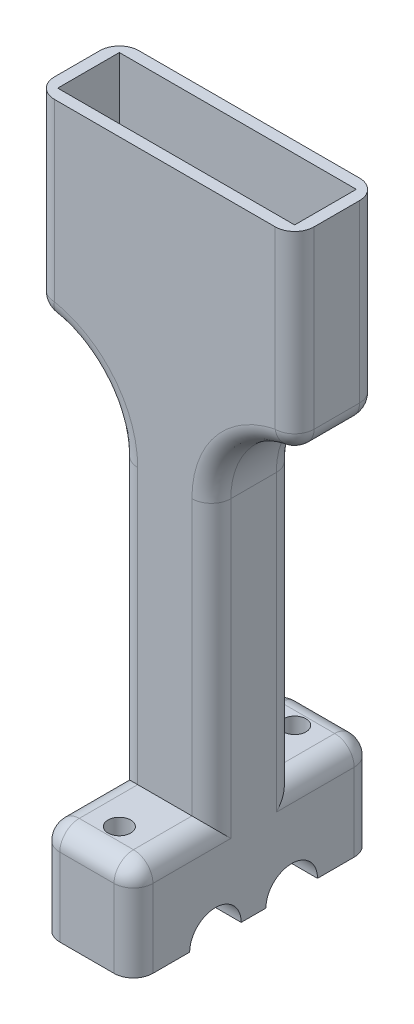
from build123d import *

# Parameters (mm, degrees)
RESSALTO_EXTRUS_O1_DEPTH = 6.5
FILETE1_R                = 3
FILETE2_R                = 3
FILETE3_R                = 13
ESBO_O4_W                = 36.5
ESBO_O4_H                = 9.5
CORTE_EXTRUS_O1_DEPTH    = 25
ESBO_O11_W               = 14.347963754
ESBO_O11_H               = 15
RESSALTO_EXTRUS_O5_DEPTH = 12
ESBO_O17_W               = 14.347963754
ESBO_O17_H               = 15
RESSALTO_EXTRUS_O6_DEPTH = 12
ESBO_O18_R               = 1.75
CORTE_EXTRUS_O5_DEPTH    = 25
ESBO_O19_R               = 3.96875
CORTE_EXTRUS_O6_DEPTH    = 25
FILETE14_R               = 3


with BuildPart() as part:
    # Esboço2 → Ressalto-extrusão1 (new body, symmetric)
    with BuildSketch(Plane.XY):
        Polygon((-20, 50), (20, 50), (20, 20), (7.173981877, 20), (7.173981877, -50), (-7.173981877, -50), (-7.173981877, 20), (-20, 20), align=None)
    extrude(amount=RESSALTO_EXTRUS_O1_DEPTH, both=True)

    # Filete1
    filete1_edges = [part.edges().sort_by_distance(p)[0] for p in [
        (-20, 20, 0),
    ]]
    fillet(filete1_edges, radius=FILETE1_R)

    # Filete2
    filete2_edges = [part.edges().sort_by_distance(p)[0] for p in [
        (20, 20, 0),
    ]]
    fillet(filete2_edges, radius=FILETE2_R)

    # Filete3
    filete3_edges = [part.edges().sort_by_distance(p)[0] for p in [
        (-7.173981877, 20, 0),
        (7.173981877, 20, 0),
    ]]
    fillet(filete3_edges, radius=FILETE3_R)

    # Esboço4 → Corte-extrusão1 (cut)
    with BuildSketch(Plane(origin=(0, 50, 0), x_dir=(1, 0, 0), z_dir=(0, 1, 0))):
        Rectangle(ESBO_O4_W, ESBO_O4_H)
    extrude(amount=-CORTE_EXTRUS_O1_DEPTH, mode=Mode.SUBTRACT)

    # Esboço11 → Ressalto-extrusão5 (add)
    with BuildSketch(Plane.XY.offset(6.5)):
        with Locations((0, -42.5)):
            Rectangle(ESBO_O11_W, ESBO_O11_H)
    extrude(amount=RESSALTO_EXTRUS_O5_DEPTH)

    # Esboço17 → Ressalto-extrusão6 (add)
    with BuildSketch(Plane(origin=(0, 0, -6.5), x_dir=(-1, 0, 0), z_dir=(0, 0, -1))):
        with Locations((0, -42.5)):
            Rectangle(ESBO_O17_W, ESBO_O17_H)
    extrude(amount=RESSALTO_EXTRUS_O6_DEPTH)

    # Esboço18 → Corte-extrusão5 (cut)
    with BuildSketch(Plane.XZ.offset(50)):
        with Locations((0, 13.5)):
            Circle(ESBO_O18_R)
        with Locations((0, -13.5)):
            Circle(ESBO_O18_R)
    extrude(amount=-CORTE_EXTRUS_O5_DEPTH, mode=Mode.SUBTRACT)

    # Esboço19 → Corte-extrusão6 (cut)
    with BuildSketch(Plane.ZY.offset(7.173981877)):
        with Locations((-5.875, -50)):
            Circle(ESBO_O19_R)
        with Locations((5.875, -50)):
            Circle(ESBO_O19_R)
    extrude(amount=-CORTE_EXTRUS_O6_DEPTH, mode=Mode.SUBTRACT)

    # Filete14
    filete14_edges = [part.edges().sort_by_distance(p)[0] for p in [
        (20, 36.5, 6.5),
        (19.322214978, 21.100706027, 6.5),
        (10.111050307, 15.548251086, 6.5),
        (-20, 36.5, 6.5),
        (-19.322214978, 21.100706027, 6.5),
        (-10.111050307, 15.548251086, 6.5),
        (20, 36.5, -6.5),
        (19.322214978, 21.100706027, -6.5),
        (10.111050307, 15.548251086, -6.5),
        (-20, 36.5, -6.5),
        (-19.322214978, 21.100706027, -6.5),
        (-10.111050307, 15.548251086, -6.5),
        (-7.173981877, -42.5, 18.5),
        (-7.173981877, -35, 12.5),
        (0, -35, -18.5),
        (-7.173981877, -35, -12.5),
        (-7.173981877, -42.5, -18.5),
        (7.173981877, -42.5, -18.5),
        (7.173981877, -35, -12.5),
        (7.173981877, -42.5, 18.5),
        (7.173981877, -35, 12.5),
        (0, -35, 18.5),
        (7.173981877, -13.841011399, 6.5),
        (-7.173981877, -13.841011399, 6.5),
        (7.173981877, -13.841011399, -6.5),
        (-7.173981877, -13.841011399, -6.5),
    ]]
    fillet(filete14_edges, radius=FILETE14_R)


solid = part.part
